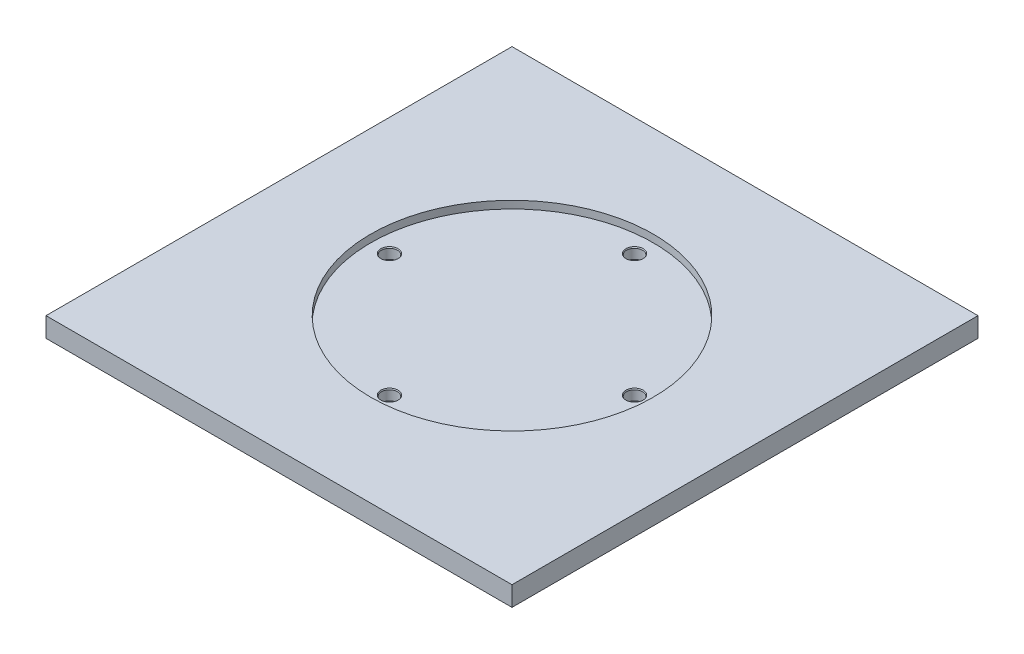
from build123d import *

# Parameters (mm, degrees)
SKETCH1_W           = 154
SKETCH1_H           = 154
BOSS_EXTRUDE1_DEPTH = 6.5
SKETCH2_R           = 46.7
CUT_EXTRUDE1_DEPTH  = 2.5
SKETCH3_R           = 2.65
CUT_EXTRUDE2_DEPTH  = 3.5
CHAMFER1_SIZE       = 0.2
CHAMFER1_SIZE2      = 0.346410162


with BuildPart() as part:
    # Sketch1 → Boss-Extrude1 (new body)
    with BuildSketch(Plane(origin=(0, 0, 0), x_dir=(1, 0, 0), z_dir=(0, 1, 0))):
        Rectangle(SKETCH1_W, SKETCH1_H)
    extrude(amount=BOSS_EXTRUDE1_DEPTH)

    # Sketch2 → Cut-Extrude1 (cut)
    with BuildSketch(Plane(origin=(0, 6.5, 0), x_dir=(1, 0, 0), z_dir=(0, 1, 0))):
        Circle(SKETCH2_R)
    extrude(amount=-CUT_EXTRUDE1_DEPTH, mode=Mode.SUBTRACT)

    # Sketch3 → Cut-Extrude2 (cut)
    with BuildSketch(Plane(origin=(0, 4, 0), x_dir=(1, 0, 0), z_dir=(0, 1, 0))):
        with Locations((0, 40.5)):
            Circle(SKETCH3_R)
        with Locations((-40.5, 0)):
            Circle(SKETCH3_R)
        with Locations((0, -40.5)):
            Circle(SKETCH3_R)
        with Locations((40.5, 0)):
            Circle(SKETCH3_R)
    extrude(amount=-CUT_EXTRUDE2_DEPTH, mode=Mode.SUBTRACT)

    # Chamfer1
    chamfer1_edges = [part.edges().sort_by_distance(p)[0] for p in [
        (-2.65, 4, -40.5),
        (-43.15, 4, 0),
        (-2.65, 4, 40.5),
        (37.85, 4, 0),
    ]]
    chamfer1_side = [part.faces().sort_by_distance(p)[0] for p in [
        (0, 4, 0),
    ]]
    chamfer(chamfer1_edges, length=CHAMFER1_SIZE, length2=CHAMFER1_SIZE2, reference=chamfer1_side[0])


solid = part.part
